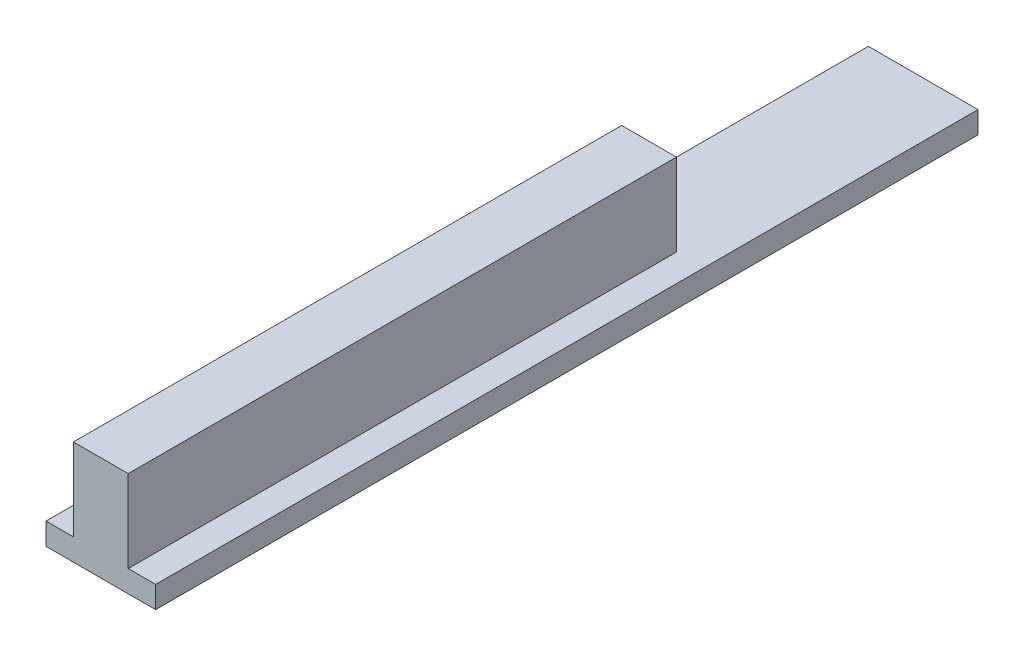
from build123d import *

# Parameters (mm, degrees)
BOSS_EXTRUDE1_DEPTH = 100
BOSS_EXTRUDE2_DEPTH = 50


with BuildPart() as part:
    # Sketch1 → Boss-Extrude1 (new body)
    with BuildSketch(Plane.XY):
        Polygon((-10, 0), (10, 0), (10, 4), (5, 4), (5, 19), (-5, 19), (-5, 4), (-10, 4), align=None)
    extrude(amount=BOSS_EXTRUDE1_DEPTH)

    # Sketch1_3 → Boss-Extrude2 (add)
    with BuildSketch(Plane.XY):
        Polygon((-10, 0), (10, 0), (10, 4), (5, 4), (-5, 4), (-10, 4), align=None)
    extrude(amount=-BOSS_EXTRUDE2_DEPTH)


solid = part.part
